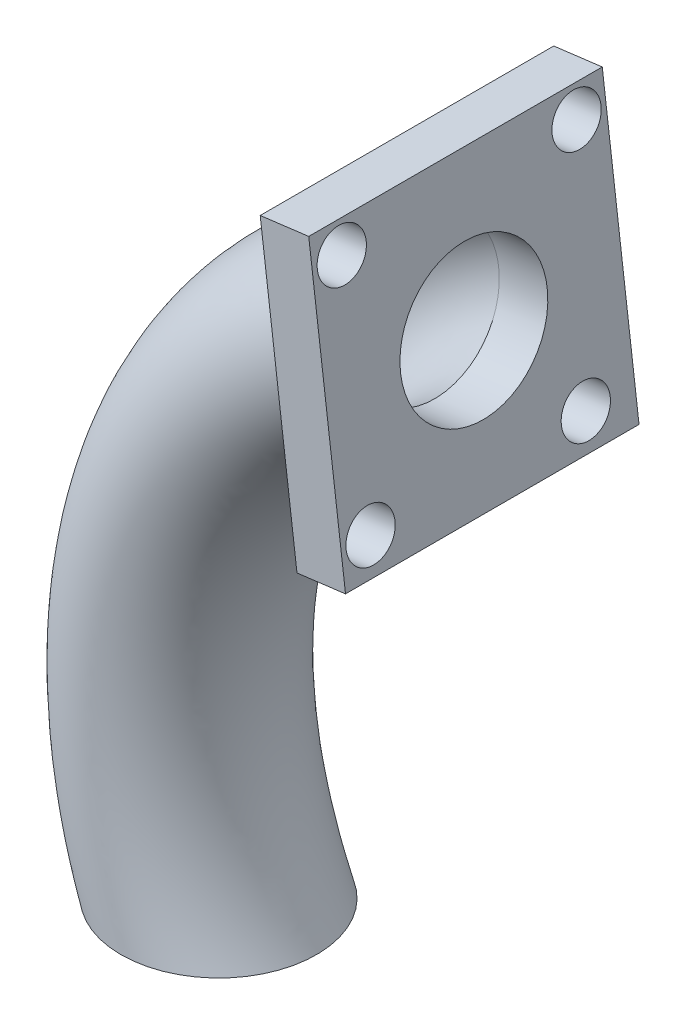
from build123d import *

# Parameters (mm, degrees)
SKETCH1_R           = 10
SKETCH1_R_2         = 7.5
SKETCH4_W           = 30
SKETCH4_H           = 30
SKETCH4_R           = 2.5
SKETCH4_R_2         = 7.5
BOSS_EXTRUDE3_DEPTH = 5


with BuildPart() as part:
    # Sweep3: sweep along a path in Sketch2
    with BuildLine(Plane.XY) as sweep3_path:
        ThreePointArc((0, 0), (-1.281289086, 35.324459387), (21.11820567, 62.668960981))
    # Sketch1 → Sweep3 (sweep)
    with BuildSketch(Plane(origin=(0, 0, 0), x_dir=(1, 0, 0), z_dir=(0, 1, 0))):
        Circle(SKETCH1_R)
        Circle(SKETCH1_R_2, mode=Mode.SUBTRACT)
    sweep(path=sweep3_path.line)

    # Sketch4 → Boss-Extrude3 (add)
    with BuildSketch(Plane(origin=(28.578554789, 3.610056753, 0), x_dir=(0, 0, -1), z_dir=(0.992115799, 0.125324544, 0))):
        with Locations((0, 59.528236809)):
            Rectangle(SKETCH4_W, SKETCH4_H)
        with Locations((-12, 71.528236809)):
            Circle(SKETCH4_R, mode=Mode.SUBTRACT)
        with Locations((12, 71.528236809)):
            Circle(SKETCH4_R, mode=Mode.SUBTRACT)
        with Locations((10, 48.035708089)):
            Circle(SKETCH4_R, mode=Mode.SUBTRACT)
        with Locations((-12, 48.035708089)):
            Circle(SKETCH4_R, mode=Mode.SUBTRACT)
        with Locations((0, 59.528236809)):
            Circle(SKETCH4_R_2, mode=Mode.SUBTRACT)
    extrude(amount=BOSS_EXTRUDE3_DEPTH)


solid = part.part
